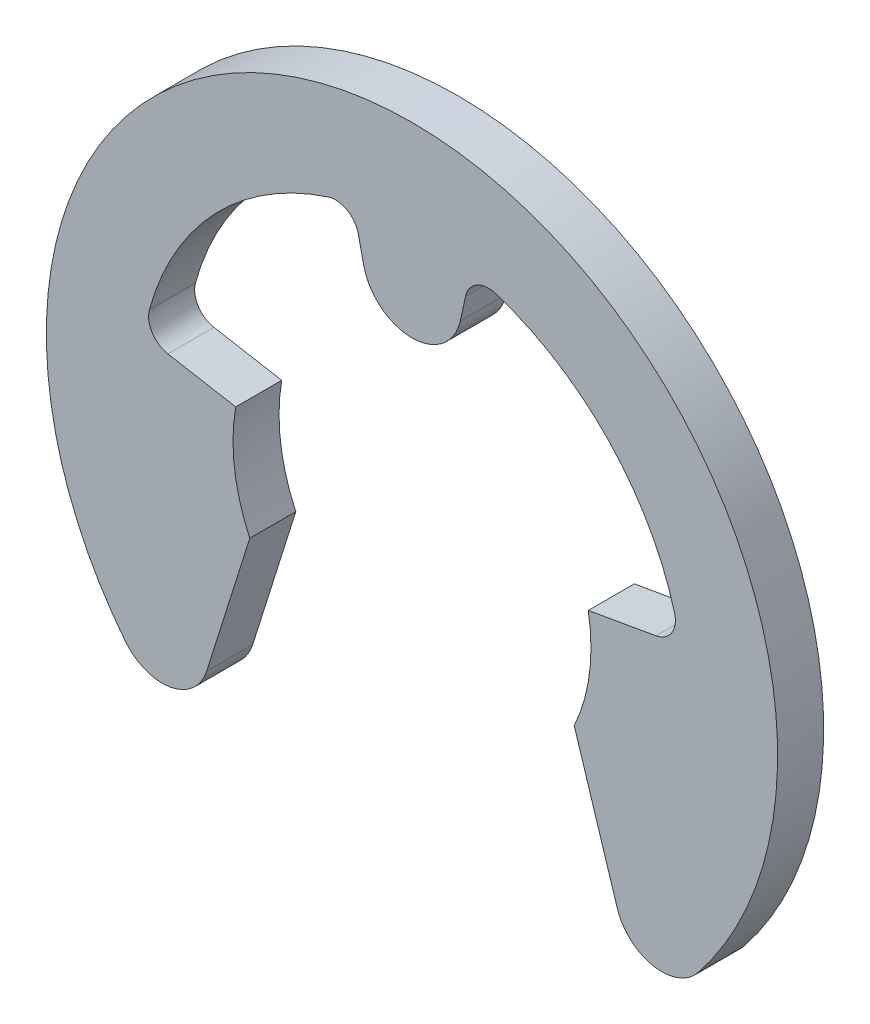
from build123d import *

# Parameters (mm, degrees)
BODY_DEPTH = 0.9


with BuildPart() as part:
    # BodySke → Body (new body)
    with BuildSketch(Plane.XY):
        with BuildLine():
            Line((3.446827136, 0.607768622), (4.77368353, 0.841729204))
            ThreePointArc((4.77368353, 0.841729204), (5.080058469, 1.047172318), (5.13437353, 1.412031676))
            ThreePointArc((5.13437353, 1.412031676), (3.846588098, 3.682307022), (1.634645962, 5.067894788))
            ThreePointArc((1.634645962, 5.067894788), (1.267764681, 5.029546364), (1.049153215, 4.732424329))
            Line((1.049153215, 4.732424329), (0.943873594, 4.257538649))
            ThreePointArc((0.943873594, 4.257538649), (0, 3.5), (-0.943873594, 4.257538649))
            Line((-0.943873594, 4.257538649), (-1.049153215, 4.732424329))
            ThreePointArc((-1.049153215, 4.732424329), (-1.267764681, 5.029546364), (-1.634645962, 5.067894788))
            ThreePointArc((-1.634645962, 5.067894788), (-3.846588098, 3.682307022), (-5.13437353, 1.412031676))
            ThreePointArc((-5.13437353, 1.412031676), (-5.080058469, 1.047172318), (-4.77368353, 0.841729204))
            Line((-4.77368353, 0.841729204), (-3.446827136, 0.607768622))
            ThreePointArc((-3.446827136, 0.607768622), (-3.470057015, -0.456841673), (-3.172077255, -1.479163916))
            Line((-3.172077255, -1.479163916), (-4.015008754, -4.152601078))
            ThreePointArc((-4.015008754, -4.152601078), (-4.71941991, -4.775507534), (-5.59995505, -4.445559969))
            ThreePointArc((-5.59995505, -4.445559969), (0, 7.15), (5.59995505, -4.445559969))
            ThreePointArc((5.59995505, -4.445559969), (4.71941991, -4.775507534), (4.015008754, -4.152601078))
            Line((4.015008754, -4.152601078), (3.172077255, -1.479163916))
            ThreePointArc((3.172077255, -1.479163916), (3.470057015, -0.456841673), (3.446827136, 0.607768622))
        make_face()
    extrude(amount=-BODY_DEPTH)


solid = part.part
